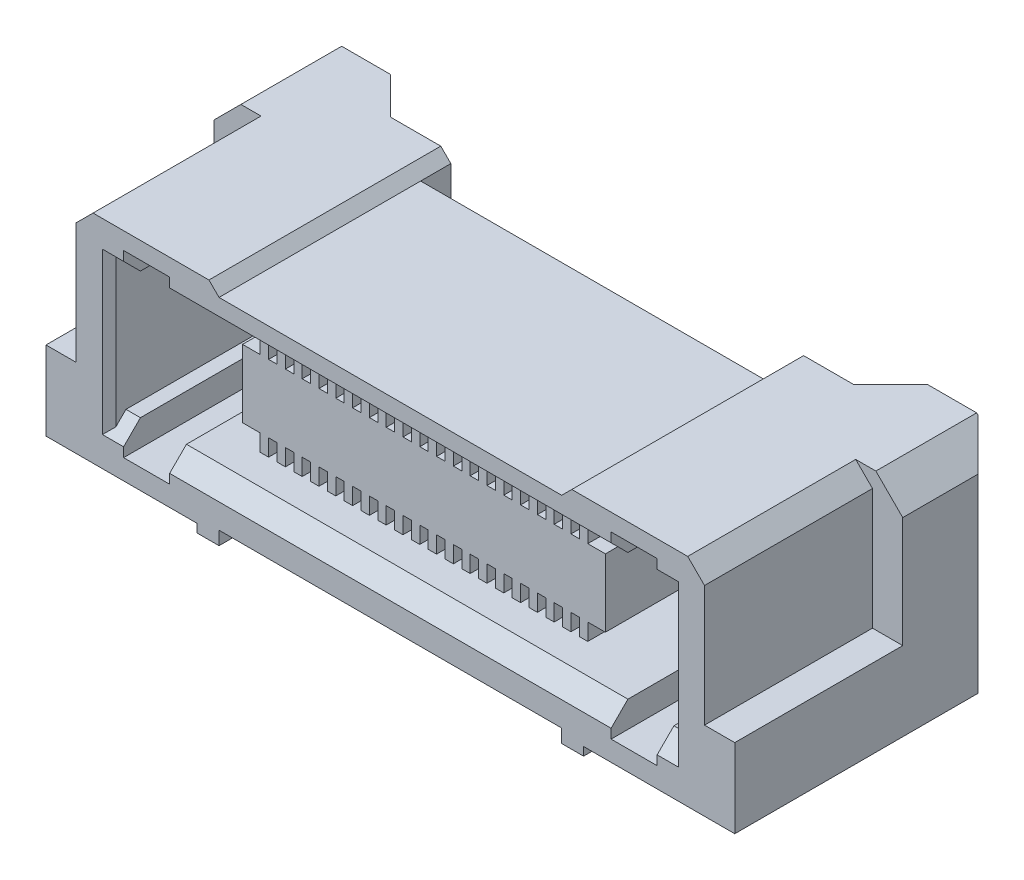
from build123d import *

# Parameters (mm, degrees)
EXTRUDE_1_DEPTH     = 8
CUT_EXTRUDE_1_DEPTH = 7.7
CUT_EXTRUDE_2_DEPTH = 5
CUT_EXTRUDE_3_DEPTH = 5
EXTRUDE_2_DEPTH     = 4
CHAMFER_1_SIZE      = 0.5
CHAMFER_2_SIZE      = 0.2
EXTRUDE_3_DEPTH     = 0.075
EXTRUDE_3_2_DEPTH   = 0.075


with BuildPart() as part:
    # Эскиз1 → Бобышка-Вытянуть1 (new body)
    with BuildSketch(Plane.XY):
        Polygon((5.1, 0), (-5.1, 0), (-5.1, -0.4), (-5.75, -0.4), (-5.75, -0.15), (-10.25, -0.15), (-10.25, 5.5), (-9.45, 6.3), (-5.4, 6.3), (-5.1, 6), (5.1, 6), (5.4, 6.3), (9.45, 6.3), (10.25, 5.5), (10.25, -0.15), (5.75, -0.15), (5.75, -0.4), (5.1, -0.4), align=None)
    extrude(amount=EXTRUDE_1_DEPTH)

    # Эскиз2 → Вырез-Вытянуть1 (cut, through all)
    with BuildSketch(Plane(origin=(0, 6.3, 0), x_dir=(1, 0, 0), z_dir=(0, 1, 0))):
        Polygon((-10.25, -0.76), (-9.49, 0), (-8, 0), (-6.9, -1.1), (-5.1, -1.1), (-5.1, -2), (5.1, -2), (5.1, -1.1), (6.9, -1.1), (8, 0), (9.49, 0), (10.25, -0.76), (10.25, 1.970177762), (-10.25, 1.970177762), align=None)
    extrude(amount=-CUT_EXTRUDE_1_DEPTH, mode=Mode.SUBTRACT)

    # Эскиз3 → Вырез-Вытянуть2 (cut)
    with BuildSketch(Plane.XY.offset(8)):
        Polygon((-10.25, 2.2), (-9.35, 2.2), (-9.35, 5.8), (-8.85, 6.3), (-9.45, 6.3), (-10.25, 5.5), align=None)
        Polygon((10.25, 5.5), (10.25, 2.2), (9.35, 2.2), (9.35, 5.8), (8.85, 6.3), (9.45, 6.3), align=None)
    extrude(amount=-CUT_EXTRUDE_2_DEPTH, mode=Mode.SUBTRACT)

    # Эскиз5 → Вырез-Вытянуть3 (cut)
    with BuildSketch(Plane.XY.offset(8)):
        Polygon((-8.37, 1.23), (-7.94, 1.23), (-7.94, 0.45), (-6.57, 0.45), (-6.57, 1.23), (6.57, 1.23), (6.57, 0.45), (7.94, 0.45), (7.94, 1.23), (8.37, 1.23), (8.37, 5.01), (7.94, 5.01), (7.94, 5.79), (6.57, 5.79), (6.57, 5.01), (-6.57, 5.01), (-6.57, 5.79), (-7.94, 5.79), (-7.94, 5.01), (-8.37, 5.01), align=None)
    extrude(amount=-CUT_EXTRUDE_3_DEPTH, mode=Mode.SUBTRACT)

    # Эскиз6 → Бобышка-Вытянуть2 (add)
    with BuildSketch(Plane.XY.offset(3)):
        Polygon((-5.4, 4.140173105), (-5.4, 2.12), (-4.875, 2.12), (-4.875, 1.62), (-4.625, 1.62), (-4.625, 2.12), (-4.375, 2.12), (-4.375, 1.62), (-4.125, 1.62), (-4.125, 2.12), (-3.875, 2.12), (-3.875, 1.62), (-3.625, 1.62), (-3.625, 2.12), (-3.375, 2.12), (-3.375, 1.62), (-3.125, 1.62), (-3.125, 2.12), (-2.875, 2.12), (-2.875, 1.62), (-2.625, 1.62), (-2.625, 2.12), (-2.375, 2.12), (-2.375, 1.62), (-2.125, 1.62), (-2.125, 2.12), (-1.875, 2.12), (-1.875, 1.62), (-1.625, 1.62), (-1.625, 2.12), (-1.375, 2.12), (-1.375, 1.62), (-1.125, 1.62), (-1.125, 2.12), (-0.875, 2.12), (-0.875, 1.62), (-0.625, 1.62), (-0.625, 2.12), (-0.375, 2.12), (-0.375, 1.62), (-0.125, 1.62), (-0.125, 2.12), (0.125, 2.12), (0.125, 1.62), (0.375, 1.62), (0.375, 2.12), (0.625, 2.12), (0.625, 1.62), (0.875, 1.62), (0.875, 2.12), (1.125, 2.12), (1.125, 1.62), (1.375, 1.62), (1.375, 2.12), (1.625, 2.12), (1.625, 1.62), (1.875, 1.62), (1.875, 2.12), (2.125, 2.12), (2.125, 1.62), (2.375, 1.62), (2.375, 2.12), (2.625, 2.12), (2.625, 1.62), (2.875, 1.62), (2.875, 2.12), (3.125, 2.12), (3.125, 1.62), (3.375, 1.62), (3.375, 2.12), (3.625, 2.12), (3.625, 1.62), (3.875, 1.62), (3.875, 2.12), (4.125, 2.12), (4.125, 1.62), (4.375, 1.62), (4.375, 2.12), (4.625, 2.12), (4.625, 1.62), (4.875, 1.62), (4.875, 2.12), (5.4, 2.12), (5.4, 4.140173105), (4.875, 4.140173105), (4.875, 4.640173105), (4.625, 4.640173105), (4.625, 4.140173105), (4.375, 4.140173105), (4.375, 4.640173105), (4.125, 4.640173105), (4.125, 4.140173105), (3.875, 4.140173105), (3.875, 4.640173105), (3.625, 4.640173105), (3.625, 4.140173105), (3.375, 4.140173105), (3.375, 4.640173105), (3.125, 4.640173105), (3.125, 4.140173105), (2.875, 4.140173105), (2.875, 4.640173105), (2.625, 4.640173105), (2.625, 4.140173105), (2.375, 4.140173105), (2.375, 4.640173105), (2.125, 4.640173105), (2.125, 4.140173105), (1.875, 4.140173105), (1.875, 4.640173105), (1.625, 4.640173105), (1.625, 4.140173105), (1.375, 4.140173105), (1.375, 4.640173105), (1.125, 4.640173105), (1.125, 4.140173105), (0.875, 4.140173105), (0.875, 4.640173105), (0.625, 4.640173105), (0.625, 4.140173105), (0.375, 4.140173105), (0.375, 4.640173105), (0.125, 4.640173105), (0.125, 4.140173105), (-0.125, 4.140173105), (-0.125, 4.640173105), (-0.375, 4.640173105), (-0.375, 4.140173105), (-0.625, 4.140173105), (-0.625, 4.640173105), (-0.875, 4.640173105), (-0.875, 4.140173105), (-1.125, 4.140173105), (-1.125, 4.640173105), (-1.375, 4.640173105), (-1.375, 4.140173105), (-1.625, 4.140173105), (-1.625, 4.640173105), (-1.875, 4.640173105), (-1.875, 4.140173105), (-2.125, 4.140173105), (-2.125, 4.640173105), (-2.375, 4.640173105), (-2.375, 4.140173105), (-2.625, 4.140173105), (-2.625, 4.640173105), (-2.875, 4.640173105), (-2.875, 4.140173105), (-3.125, 4.140173105), (-3.125, 4.640173105), (-3.375, 4.640173105), (-3.375, 4.140173105), (-3.625, 4.140173105), (-3.625, 4.640173105), (-3.875, 4.640173105), (-3.875, 4.140173105), (-4.125, 4.140173105), (-4.125, 4.640173105), (-4.375, 4.640173105), (-4.375, 4.140173105), (-4.625, 4.140173105), (-4.625, 4.640173105), (-4.875, 4.640173105), (-4.875, 4.140173105), align=None)
    extrude(amount=EXTRUDE_2_DEPTH)

    # Фаска1
    chamfer_1_edges = [part.edges().sort_by_distance(p)[0] for p in [
        (-8.155, 1.23, 8),
        (0, 1.23, 8),
        (8.155, 1.23, 8),
        (8.155, 5.01, 8),
        (0, 5.01, 8),
        (-8.155, 5.01, 8),
    ]]
    chamfer(chamfer_1_edges, length=CHAMFER_1_SIZE)

    # Фаска2
    chamfer_2_edges = [part.edges().sort_by_distance(p)[0] for p in [
        (-8.37, 3.12, 8),
        (8.37, 3.12, 8),
    ]]
    chamfer(chamfer_2_edges, length=CHAMFER_2_SIZE)


with BuildPart() as body_2:
    # Эскиз8 → Бобышка-Вытянуть3 (new body, symmetric)
    with BuildSketch(Plane.XY.offset(0.4)):
        Polygon((-7.29, -0.15), (-6.79, -0.65), (-6.79, -1.922237412), (-6.602950802, -2.280680045), (-6.602950802, -2.4), (-6.197049198, -2.4), (-6.197049198, -2.280680045), (-6.01, -1.922237412), (-6.01, -0.15), align=None)
    extrude(amount=EXTRUDE_3_DEPTH, both=True)


with BuildPart() as body_3:
    # Эскиз8 → Extrude 3 2 (new body, symmetric)
    with BuildSketch(Plane.XY.offset(0.4)):
        Polygon((6.01, -0.15), (7.29, -0.15), (6.79, -0.65), (6.79, -1.922237412), (6.602950802, -2.280680045), (6.602950802, -2.4), (6.197049198, -2.4), (6.197049198, -2.280680045), (6.01, -1.922237412), align=None)
    extrude(amount=EXTRUDE_3_2_DEPTH, both=True)


solid = Compound([part.part, body_2.part, body_3.part])
